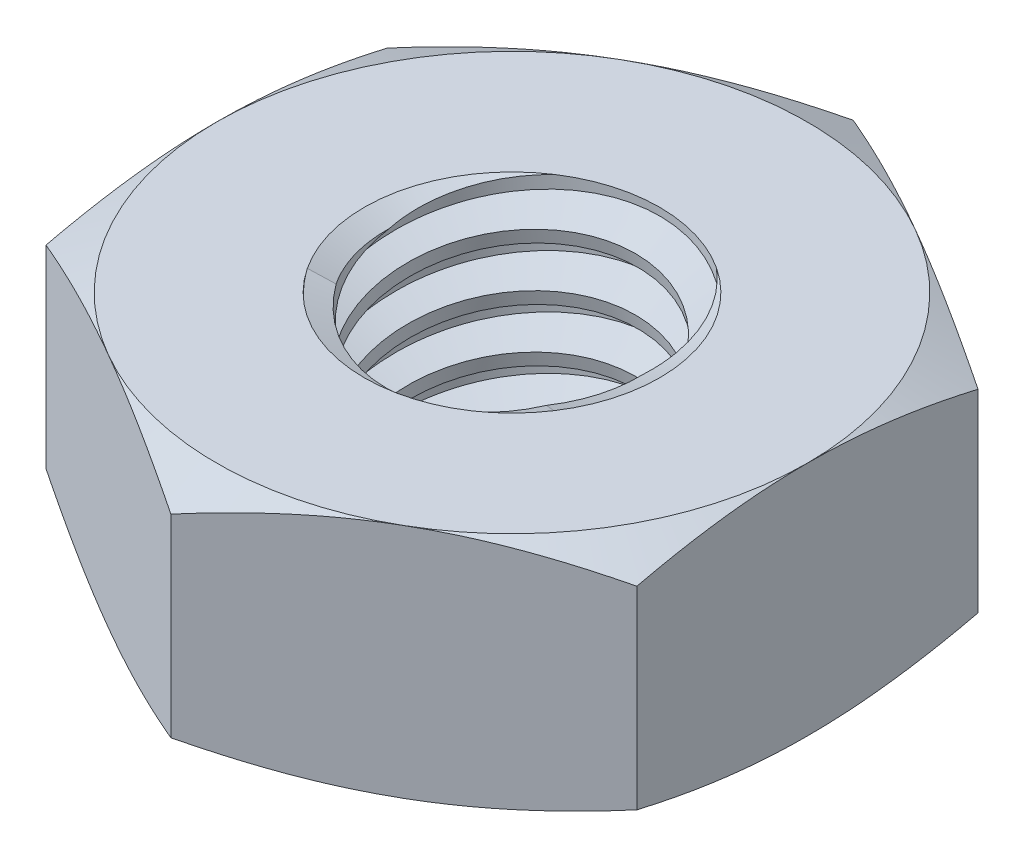
from build123d import *

# Parameters (mm, degrees)
EXTRUDE1_DEPTH      = 1
SKETCH2_W           = 1.25
SKETCH2_H           = 2
LPATTERN1_COUNT     = 4
LPATTERN1_PITCH     = 0.45
LPATTERN1_COL_COUNT = 2
LPATTERN1_COL_PITCH = 0.45


with BuildPart() as part:
    # Sketch1 → Extrude1 (new body, symmetric)
    with BuildSketch(Plane(origin=(0, 0, 0), x_dir=(1, 0, 0), z_dir=(0, 1, 0))):
        Polygon((0, 2.886751346), (-2.5, 1.443375673), (-2.5, -1.443375673), (0, -2.886751346), (2.5, -1.443375673), (2.5, 1.443375673), align=None)
    extrude(amount=EXTRUDE1_DEPTH, both=True)

    # Sketch4 → Cut-Revolve2 (revolve, cut)
    with BuildSketch(Plane(origin=(0, 0, 0), x_dir=(0, 0, -1), z_dir=(1, 0, 0))):
        Polygon((0, 1), (1.25, 1), (1.045159814, 0.904481453), (1.045159814, -0.904481453), (1.25, -1), (0, -1), align=None)
    revolve(axis=Axis((0, 1, 0), (0, 1, 0)), mode=Mode.SUBTRACT)


with BuildPart() as body_2:
    # Sketch2 → Revolve1 (revolve)
    with BuildSketch(Plane(origin=(0, 0, 0), x_dir=(0, 0, -1), z_dir=(1, 0, 0))):
        with Locations((0.625, 0)):
            Rectangle(SKETCH2_W, SKETCH2_H)
    revolve(axis=Axis((0, -2.25, 0), (0, 1, 0)))

    # Sketch3 → Cut-Revolve1 (revolve, cut)
    with BuildSketch(Plane(origin=(0, 0, 0), x_dir=(0, 0, -1), z_dir=(1, 0, 0))):
        Polygon((1.259964856, 0.944639688), (1.329718849, 0.557117504), (1.065089526, 0.652369191), (1.045159814, 0.763089815), align=None)
    cut_revolve1 = revolve(axis=Axis((0, 1, 0.086794729), (0, -0.984183324, -0.177152998)), mode=Mode.SUBTRACT)

    # LPattern1: Cut-Revolve1 ×4
    with Locations(*[(0, -i * LPATTERN1_PITCH, 0) for i in range(1, LPATTERN1_COUNT)]):
        add(cut_revolve1, mode=Mode.SUBTRACT)

    # LPattern1 col: Cut-Revolve1 ×2
    with Locations(*[(0, i * LPATTERN1_COL_PITCH, 0) for i in range(1, LPATTERN1_COL_COUNT)]):
        add(cut_revolve1, mode=Mode.SUBTRACT)


with BuildPart() as part_1:
    add(part.part)

    # Combine1: cut body 2
    add(body_2.part, mode=Mode.SUBTRACT)

    # Sketch5 → Cut-Revolve3 (revolve, cut)
    with BuildSketch(Plane(origin=(0, 0, 0), x_dir=(0, 0, -1), z_dir=(1, 0, 0))):
        Polygon((0, -1), (2.5, -1), (2.886751346, -0.819654886), (2.886751346, 0.819654886), (2.5, 1), (0, 1), (0, 2.27), (4.156751346, 2.27), (4.156751346, -2.27), (0, -2.27), align=None)
    revolve(axis=Axis((0, -1, 0), (0, 1, 0)), mode=Mode.SUBTRACT)


solid = part_1.part
